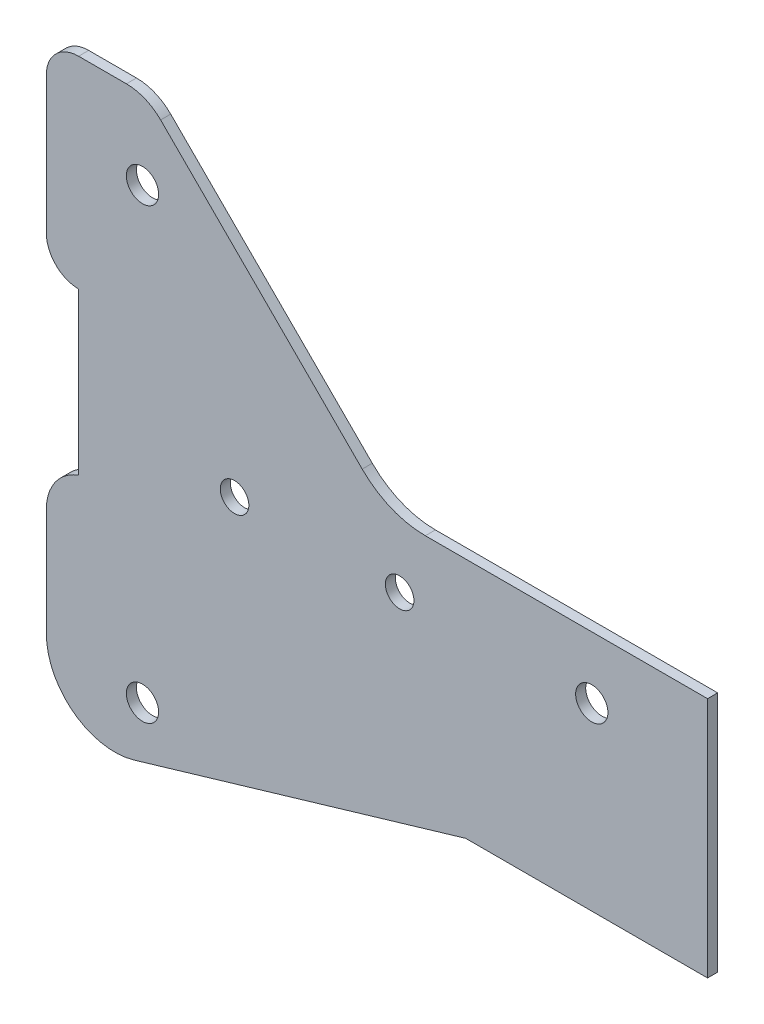
from build123d import *

# Parameters (mm, degrees)
SKETCH1_R           = 2.54
SKETCH1_R_2         = 2.25
BOSS_EXTRUDE1_DEPTH = 1.5875


with BuildPart() as part:
    # Sketch1 → Boss-Extrude1 (new body)
    with BuildSketch(Plane.XY):
        with BuildLine():
            Line((0, 0), (-44.45, 0))
            ThreePointArc((-44.45, 0), (-49.830627072, 1.070273269), (-54.392102448, 4.118153673))
            Line((-54.392102448, 4.118153673), (-86.142102448, 35.868153673))
            ThreePointArc((-86.142102448, 35.868153673), (-88.614208366, 37.519962038), (-91.530256121, 38.1))
            Line((-91.530256121, 38.1), (-99.06, 38.1))
            ThreePointArc((-99.06, 38.1), (-102.652102448, 36.612102448), (-104.14, 33.02))
            Line((-104.14, 33.02), (-104.14, 11.43))
            ThreePointArc((-104.14, 11.43), (-102.652102448, 7.837897552), (-99.06, 6.35))
            Line((-99.06, 6.35), (-99.06, -19.05))
            ThreePointArc((-99.06, -19.05), (-102.741703947, -21.834795846), (-104.14, -26.234204897))
            Line((-104.14, -26.234204897), (-104.14, -43.199318572))
            ThreePointArc((-104.14, -43.199318572), (-99.814124397, -51.831543955), (-90.309725681, -53.532990354))
            Line((-90.309725681, -53.532990354), (-38.1, -38.1))
            Line((-38.1, -38.1), (0, -38.1))
            Line((0, -38.1), (0, 0))
        make_face()
        with Locations((-89, 25.555)):
            Circle(SKETCH1_R, mode=Mode.SUBTRACT)
        with Locations((-89, -45.055)):
            Circle(SKETCH1_R, mode=Mode.SUBTRACT)
        with Locations((-18.24, -9.75)):
            Circle(SKETCH1_R, mode=Mode.SUBTRACT)
        with Locations((-74.5, -9.75)):
            Circle(SKETCH1_R_2, mode=Mode.SUBTRACT)
        with Locations((-48.5, -9.75)):
            Circle(SKETCH1_R_2, mode=Mode.SUBTRACT)
    extrude(amount=BOSS_EXTRUDE1_DEPTH)


solid = part.part
